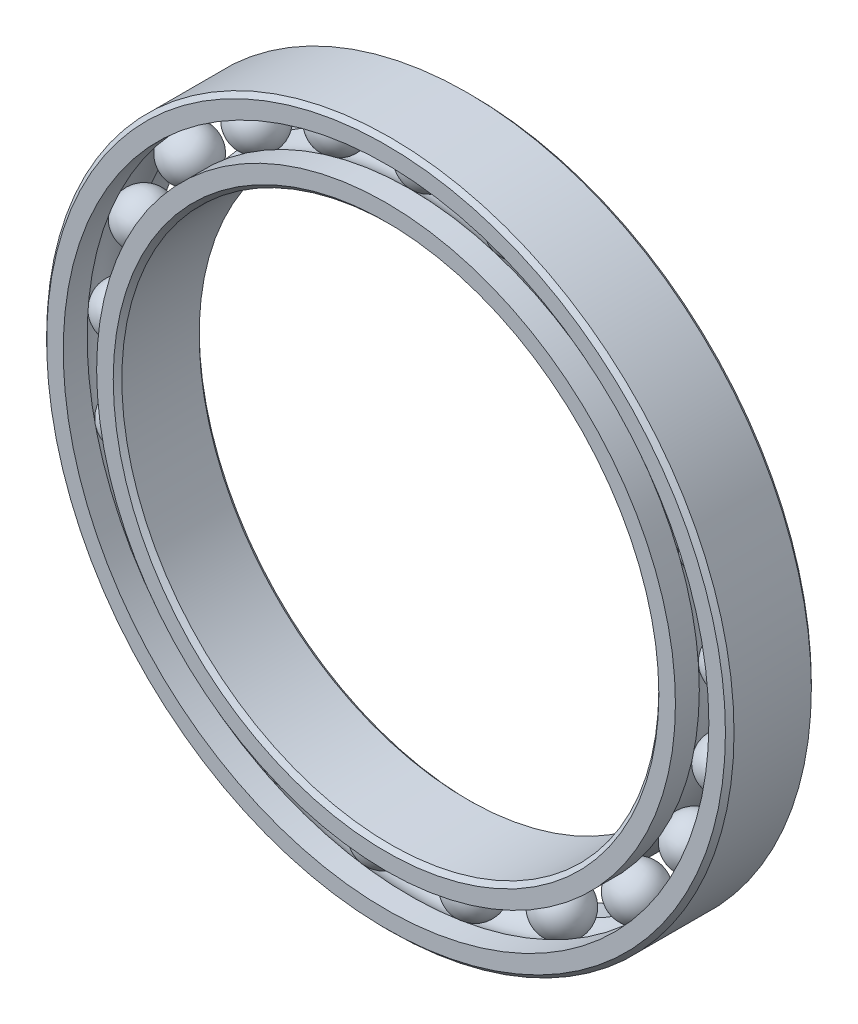
from build123d import *

# Parameters (mm, degrees)
CIRPATTERN1_COUNT = 21


with BuildPart() as part:
    # Sketch5 → Revolve1 (revolve)
    with BuildSketch(Plane(origin=(0, 0, 0), x_dir=(0, 0, -1), z_dir=(1, 0, 0))):
        with BuildLine():
            Line((1.8, 16), (-1.8, 16))
            Line((-1.8, 16), (-2, 15.8))
            Line((-2, 15.8), (-2, 15.027777778))
            Line((-2, 15.027777778), (-0.888888889, 15.027777778))
            ThreePointArc((-0.888888889, 15.027777778), (0, 15.431127313), (0.888888889, 15.027777778))
            Line((0.888888889, 15.027777778), (2, 15.027777778))
            Line((2, 15.027777778), (2, 15.8))
            Line((2, 15.8), (1.8, 16))
        make_face()
    revolve(axis=Axis((0, 0, 2), (0, 0, -1)))


with BuildPart() as body_2:
    # Sketch3 → Revolve3 (revolve)
    with BuildSketch(Plane(origin=(0, 0, 0), x_dir=(0, 0, -1), z_dir=(1, 0, 0))):
        with BuildLine():
            Line((-2, 13.472222222), (-0.888888889, 13.472222222))
            ThreePointArc((-0.888888889, 13.472222222), (0, 13.068872687), (0.888888889, 13.472222222))
            Line((0.888888889, 13.472222222), (2, 13.472222222))
            Line((2, 13.472222222), (2, 12.7))
            Line((2, 12.7), (1.8, 12.5))
            Line((1.8, 12.5), (-1.8, 12.5))
            Line((-1.8, 12.5), (-2, 12.7))
            Line((-2, 12.7), (-2, 13.472222222))
        make_face()
    revolve(axis=Axis((0, 0, 2), (0, 0, -1)))


with BuildPart() as body_3:
    # Sketch4 → Revolve4 (revolve)
    with BuildSketch(Plane(origin=(0, 0, 0), x_dir=(0, 0, -1), z_dir=(1, 0, 0))):
        with BuildLine():
            Line((-1.181127313, 14.25), (1.181127313, 14.25))
            ThreePointArc((1.181127313, 14.25), (0, 15.431127313), (-1.181127313, 14.25))
        make_face()
    revolve(axis=Axis((0, 14.25, 1.181127313), (0, 0, -1)))


with BuildPart() as cirpattern1_1:
    # CirPattern1: pattern copy
    add(body_3.part.rotate(Axis((0, 0, 0), (0, 0, 1)), 1 * 360 / CIRPATTERN1_COUNT))


with BuildPart() as cirpattern1_2:
    # CirPattern1: pattern copy
    add(body_3.part.rotate(Axis((0, 0, 0), (0, 0, 1)), 2 * 360 / CIRPATTERN1_COUNT))


with BuildPart() as cirpattern1_3:
    # CirPattern1: pattern copy
    add(body_3.part.rotate(Axis((0, 0, 0), (0, 0, 1)), 3 * 360 / CIRPATTERN1_COUNT))


with BuildPart() as cirpattern1_4:
    # CirPattern1: pattern copy
    add(body_3.part.rotate(Axis((0, 0, 0), (0, 0, 1)), 4 * 360 / CIRPATTERN1_COUNT))


with BuildPart() as cirpattern1_5:
    # CirPattern1: pattern copy
    add(body_3.part.rotate(Axis((0, 0, 0), (0, 0, 1)), 5 * 360 / CIRPATTERN1_COUNT))


with BuildPart() as cirpattern1_6:
    # CirPattern1: pattern copy
    add(body_3.part.rotate(Axis((0, 0, 0), (0, 0, 1)), 6 * 360 / CIRPATTERN1_COUNT))


with BuildPart() as cirpattern1_7:
    # CirPattern1: pattern copy
    add(body_3.part.rotate(Axis((0, 0, 0), (0, 0, 1)), 7 * 360 / CIRPATTERN1_COUNT))


with BuildPart() as cirpattern1_8:
    # CirPattern1: pattern copy
    add(body_3.part.rotate(Axis((0, 0, 0), (0, 0, 1)), 8 * 360 / CIRPATTERN1_COUNT))


with BuildPart() as cirpattern1_9:
    # CirPattern1: pattern copy
    add(body_3.part.rotate(Axis((0, 0, 0), (0, 0, 1)), 9 * 360 / CIRPATTERN1_COUNT))


with BuildPart() as cirpattern1_10:
    # CirPattern1: pattern copy
    add(body_3.part.rotate(Axis((0, 0, 0), (0, 0, 1)), 10 * 360 / CIRPATTERN1_COUNT))


with BuildPart() as cirpattern1_11:
    # CirPattern1: pattern copy
    add(body_3.part.rotate(Axis((0, 0, 0), (0, 0, 1)), 11 * 360 / CIRPATTERN1_COUNT))


with BuildPart() as cirpattern1_12:
    # CirPattern1: pattern copy
    add(body_3.part.rotate(Axis((0, 0, 0), (0, 0, 1)), 12 * 360 / CIRPATTERN1_COUNT))


with BuildPart() as cirpattern1_13:
    # CirPattern1: pattern copy
    add(body_3.part.rotate(Axis((0, 0, 0), (0, 0, 1)), 13 * 360 / CIRPATTERN1_COUNT))


with BuildPart() as cirpattern1_14:
    # CirPattern1: pattern copy
    add(body_3.part.rotate(Axis((0, 0, 0), (0, 0, 1)), 14 * 360 / CIRPATTERN1_COUNT))


with BuildPart() as cirpattern1_15:
    # CirPattern1: pattern copy
    add(body_3.part.rotate(Axis((0, 0, 0), (0, 0, 1)), 15 * 360 / CIRPATTERN1_COUNT))


with BuildPart() as cirpattern1_16:
    # CirPattern1: pattern copy
    add(body_3.part.rotate(Axis((0, 0, 0), (0, 0, 1)), 16 * 360 / CIRPATTERN1_COUNT))


with BuildPart() as cirpattern1_17:
    # CirPattern1: pattern copy
    add(body_3.part.rotate(Axis((0, 0, 0), (0, 0, 1)), 17 * 360 / CIRPATTERN1_COUNT))


with BuildPart() as cirpattern1_18:
    # CirPattern1: pattern copy
    add(body_3.part.rotate(Axis((0, 0, 0), (0, 0, 1)), 18 * 360 / CIRPATTERN1_COUNT))


with BuildPart() as cirpattern1_19:
    # CirPattern1: pattern copy
    add(body_3.part.rotate(Axis((0, 0, 0), (0, 0, 1)), 19 * 360 / CIRPATTERN1_COUNT))


with BuildPart() as cirpattern1_20:
    # CirPattern1: pattern copy
    add(body_3.part.rotate(Axis((0, 0, 0), (0, 0, 1)), 20 * 360 / CIRPATTERN1_COUNT))


solid = Compound([part.part, body_2.part, body_3.part, cirpattern1_1.part, cirpattern1_2.part, cirpattern1_3.part, cirpattern1_4.part, cirpattern1_5.part, cirpattern1_6.part, cirpattern1_7.part, cirpattern1_8.part, cirpattern1_9.part, cirpattern1_10.part, cirpattern1_11.part, cirpattern1_12.part, cirpattern1_13.part, cirpattern1_14.part, cirpattern1_15.part, cirpattern1_16.part, cirpattern1_17.part, cirpattern1_18.part, cirpattern1_19.part, cirpattern1_20.part])
